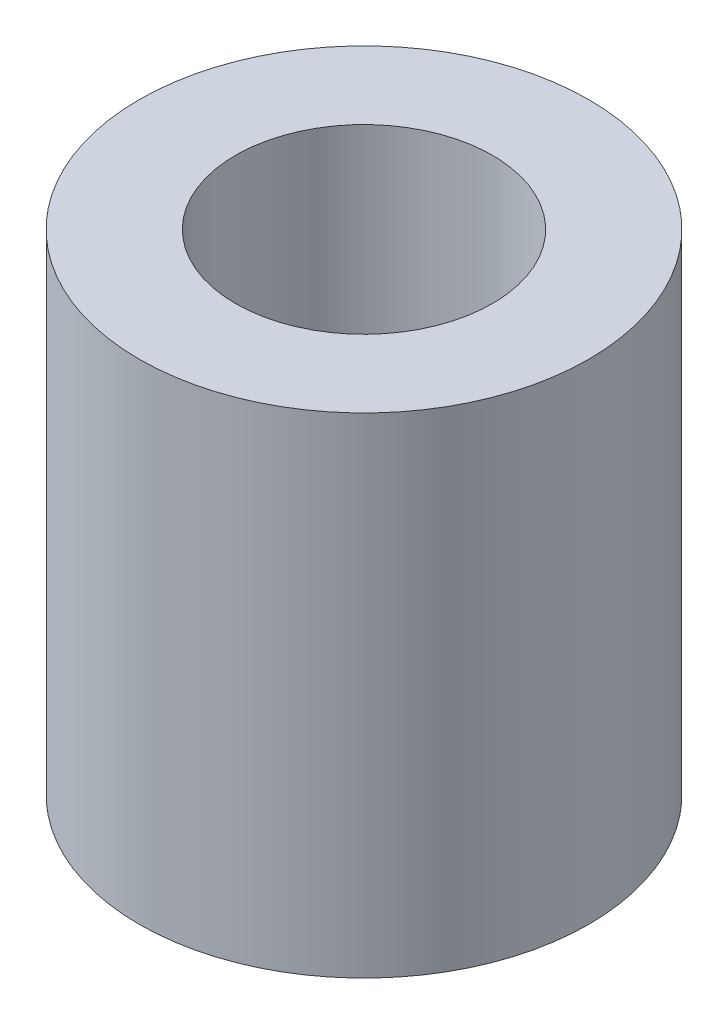
from build123d import *

# Parameters (mm, degrees)
SKETCH1_R           = 3.5
SKETCH1_R_2         = 1.999996
BOSS_EXTRUDE1_DEPTH = 7.62


with BuildPart() as part:
    # Sketch1 → Boss-Extrude1 (new body)
    with BuildSketch(Plane(origin=(0, 0, 0), x_dir=(1, 0, 0), z_dir=(0, 1, 0))):
        Circle(SKETCH1_R)
        Circle(SKETCH1_R_2, mode=Mode.SUBTRACT)
    extrude(amount=-BOSS_EXTRUDE1_DEPTH)


solid = part.part
